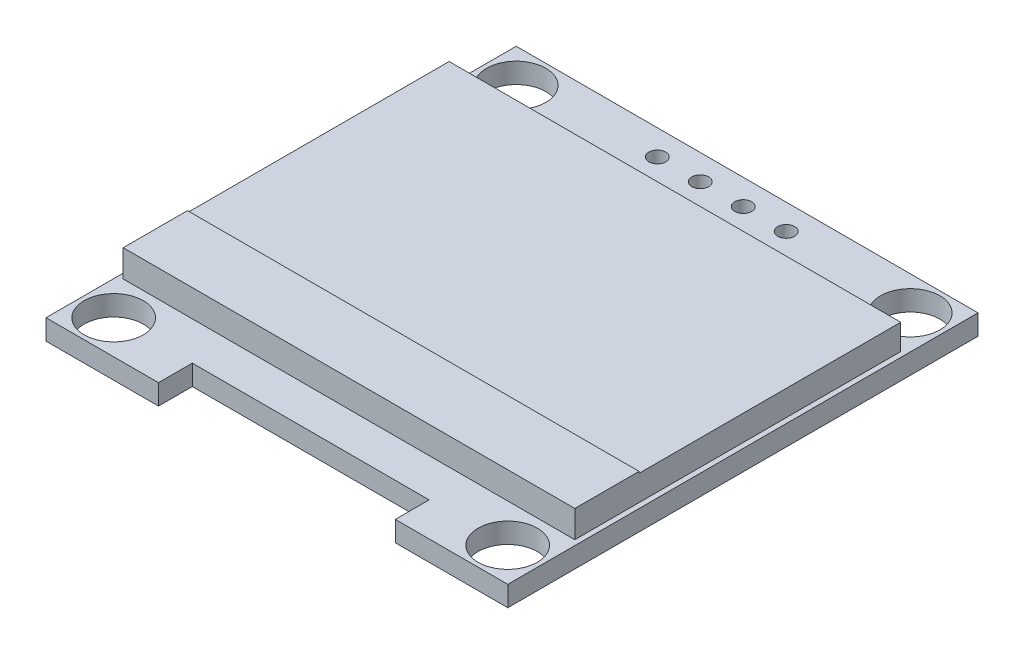
from build123d import *

# Parameters (mm, degrees)
ESQUISSE1_R             = 1.75
ESQUISSE1_R_2           = 0.5
BOSS_EXTRU_2_DEPTH      = 1.2
ESQUISSE9_W             = 26.7
ESQUISSE9_H             = 19.268
BOSS_EXTRU_3_DEPTH      = 1.5
ENL_V_MAT_EXTRU_1_DEPTH = 0.5
ESQUISSE11_W            = 26.7
ESQUISSE11_H            = 3.79988877
BOSS_EXTRU_4_DEPTH      = 0.1


with BuildPart() as part:
    # Esquisse1 → Boss.-Extru.2 (new body)
    with BuildSketch(Plane(origin=(0, 0, 0), x_dir=(1, 0, 0), z_dir=(0, 1, 0))):
        Polygon((0, 0), (0, 27.8), (27.3, 27.8), (27.3, 0), (20.65, 0), (20.65, 2.0001046), (6.65, 2.0001046), (6.65, 0), align=None)
        with Locations((25.29519694, 2.0001046)):
            Circle(ESQUISSE1_R, mode=Mode.SUBTRACT)
        with Locations((2.002692778, 2.0001046)):
            Circle(ESQUISSE1_R, mode=Mode.SUBTRACT)
        with Locations((25.29519694, 25.8)):
            Circle(ESQUISSE1_R, mode=Mode.SUBTRACT)
        with Locations((2, 25.8)):
            Circle(ESQUISSE1_R, mode=Mode.SUBTRACT)
        with Locations((9.84, 26.3)):
            Circle(ESQUISSE1_R_2, mode=Mode.SUBTRACT)
        with Locations((17.46, 26.3)):
            Circle(ESQUISSE1_R_2, mode=Mode.SUBTRACT)
        with Locations((12.38, 26.3)):
            Circle(ESQUISSE1_R_2, mode=Mode.SUBTRACT)
        with Locations((14.92, 26.3)):
            Circle(ESQUISSE1_R_2, mode=Mode.SUBTRACT)
    extrude(amount=BOSS_EXTRU_2_DEPTH)

    # Esquisse9 → Boss.-Extru.3 (add)
    with BuildSketch(Plane(origin=(0, 1.2, 0), x_dir=(1, 0, 0), z_dir=(0, 1, 0))):
        with Locations((13.64759847, 13.9000523)):
            Rectangle(ESQUISSE9_W, ESQUISSE9_H)
    extrude(amount=BOSS_EXTRU_3_DEPTH)

    # Esquisse10 → Enlèv. mat.-Extru.1 (cut)
    with BuildSketch(Plane(origin=(27.506922767, 0, -25.389295394), x_dir=(-1, 0, 0), z_dir=(0, -1, 0))):
        with BuildLine():
            add(Edge.make_bspline(
                [(4.410667941, -14.644029634), (4.475476047, -14.645671114), (4.602764514, -14.648895114), (4.789839411, -14.673574218), (4.968434507, -14.716269608), (5.140004645, -14.77313259), (5.302497622, -14.848986976), (5.457136514, -14.940672124), (5.603553388, -15.049148583), (5.73977477, -15.17357781), (5.86443172, -15.308961264), (5.974257606, -15.453439174), (6.0662999, -15.606137976), (6.141885687, -15.766598807), (6.201184297, -15.934458775), (6.242103341, -16.110612777), (6.268241491, -16.293919468), (6.271297268, -16.418946332), (6.272847428, -16.48237098)],
                knots=[0, 0, 0, 0, 0.000194393, 0.000381804, 0.00056479, 0.000744601, 0.000923091, 0.001101652, 0.001283106, 0.001468738, 0.001654324, 0.001834514, 0.002012231, 0.002188181, 0.002365797, 0.002545211, 0.002729936, 0.002920126, 0.002920126, 0.002920126, 0.002920126], degree=3))
            add(Edge.make_bspline(
                [(6.272847428, -16.48237098), (6.271297495, -16.545328427), (6.268242399, -16.669424847), (6.242073621, -16.851568291), (6.201032621, -17.026658988), (6.142436355, -17.194404641), (6.067210877, -17.354982204), (5.974555706, -17.507969158), (5.865414495, -17.653415657), (5.741207644, -17.789728322), (5.605806602, -17.914725793), (5.460576335, -18.023644668), (5.308783015, -18.117368793), (5.148473307, -18.192152467), (4.98177327, -18.251924387), (4.807190947, -18.292677017), (4.625544393, -18.31896406), (4.501673389, -18.321982576), (4.438712813, -18.323516814)],
                knots=[0, 0, 0, 0, 0.000188789, 0.000372126, 0.000550857, 0.00072758, 0.000904164, 0.001081881, 0.001263191, 0.001448823, 0.00163441, 0.001815159, 0.001992641, 0.002168591, 0.002344885, 0.002522934, 0.002705576, 0.002894365, 0.002894365, 0.002894365, 0.002894365], degree=3))
            add(Edge.make_bspline(
                [(4.438712813, -18.323516814), (4.375288494, -18.321967427), (4.250262278, -18.318913173), (4.066725242, -18.292731768), (3.890447498, -18.251790464), (3.721933147, -18.193281028), (3.561088218, -18.117663797), (3.407598135, -18.025459418), (3.262078988, -17.916052277), (3.125737241, -17.791885703), (3.000988043, -17.656714151), (2.892228667, -17.511879895), (2.800003554, -17.360224439), (2.724640221, -17.201326915), (2.664975762, -17.035955472), (2.624270944, -16.863006994), (2.597934992, -16.683467489), (2.594900145, -16.56122459), (2.593360248, -16.499197903)],
                knots=[0, 0, 0, 0, 0.00019019, 0.000374915, 0.000555011, 0.000732396, 0.00090898, 0.001087298, 0.001268608, 0.00145424, 0.001639827, 0.001819595, 0.001996712, 0.002171394, 0.002346367, 0.002523053, 0.002703612, 0.002889599, 0.002889599, 0.002889599, 0.002889599], degree=3))
            add(Edge.make_bspline(
                [(2.593360248, -16.499197903), (2.593894884, -16.457565234), (2.59495741, -16.374825111), (2.607749103, -16.251958511), (2.626310804, -16.131067853), (2.652912717, -16.012496905), (2.687704384, -15.89653592), (2.728756411, -15.782385157), (2.778896256, -15.671201434), (2.835576904, -15.562458042), (2.898838712, -15.457850136), (2.968714462, -15.358970553), (3.04274983, -15.264989556), (3.123913224, -15.178342552), (3.209529669, -15.096508896), (3.300988047, -15.020746179), (3.397730292, -14.950371228), (3.500172671, -14.886950887), (3.605790946, -14.829591752), (3.714667724, -14.780369901), (3.825324295, -14.73812384), (3.938278943, -14.703883015), (4.053231715, -14.676850979), (4.1704335, -14.658443625), (4.289790926, -14.645619307), (4.370202245, -14.644561805), (4.410667941, -14.644029634)],
                knots=[0, 0, 0, 0, 0.000124849, 0.000248123, 0.000370193, 0.00049164, 0.000612319, 0.000733199, 0.000855287, 0.000977905, 0.001100913, 0.001221706, 0.001340948, 0.001459521, 0.001577551, 0.001696047, 0.001815534, 0.001936153, 0.002057243, 0.002175846, 0.002294342, 0.002412335, 0.002529682, 0.00264829, 0.002768075, 0.00288942, 0.00288942, 0.00288942, 0.00288942], degree=3))
        make_face()
        with BuildLine():
            add(Edge.make_bspline(
                [(4.42609262, -15.003003993), (4.392877987, -15.003408883), (4.326766254, -15.004214793), (4.228481718, -15.014830509), (4.131489784, -15.029960398), (4.035770422, -15.051541918), (3.941724132, -15.080945971), (3.848474291, -15.114786879), (3.756871237, -15.15600797), (3.667217379, -15.202580674), (3.580302304, -15.254129595), (3.498289603, -15.311101362), (3.420966959, -15.372159916), (3.348523692, -15.437447754), (3.28117252, -15.507297356), (3.217587818, -15.580649792), (3.160318237, -15.659601683), (3.10783266, -15.74201209), (3.06086482, -15.827773671), (3.019099465, -15.915983533), (2.984935456, -16.00736122), (2.95707308, -16.100915378), (2.933973269, -16.196497837), (2.919339345, -16.294833686), (2.908606985, -16.395428798), (2.90784714, -16.463410652), (2.907462813, -16.49779566)],
                knots=[0, 0, 0, 0, 9.9599e-05, 0.000198245, 0.000296222, 0.00039402, 0.00049227, 0.000591646, 0.000691452, 0.000793368, 0.000894612, 0.000994383, 0.001092713, 0.00119001, 0.001286696, 0.001383657, 0.001480979, 0.001579008, 0.001676595, 0.001774142, 0.001871547, 0.001968922, 0.002066879, 0.00216624, 0.00226698, 0.002370083, 0.002370083, 0.002370083, 0.002370083], degree=3))
            add(Edge.make_bspline(
                [(2.907462813, -16.49779566), (2.908737675, -16.548357881), (2.911245722, -16.647829411), (2.933203292, -16.793597555), (2.967025267, -16.933685841), (3.016882633, -17.06732775), (3.079233248, -17.195672033), (3.156260138, -17.317580138), (3.247519224, -17.433085012), (3.35118275, -17.541380281), (3.464505457, -17.640226086), (3.584838187, -17.726989494), (3.710891794, -17.800399744), (3.842994997, -17.860204816), (3.980442536, -17.907594554), (4.124120087, -17.940073185), (4.273070547, -17.961448641), (4.374601202, -17.963501397), (4.42609262, -17.964542455)],
                knots=[0, 0, 0, 0, 0.000151605, 0.000298253, 0.000441263, 0.000583229, 0.000725274, 0.000868635, 0.001014928, 0.001166177, 0.001317744, 0.00146543, 0.001610576, 0.001754594, 0.001899821, 0.002045914, 0.002195936, 0.002350312, 0.002350312, 0.002350312, 0.002350312], degree=3))
            add(Edge.make_bspline(
                [(4.42609262, -17.964542455), (4.460702122, -17.96406695), (4.529343158, -17.963123882), (4.631438681, -17.953625206), (4.731694892, -17.938393336), (4.829971172, -17.916462681), (4.926155984, -17.889015474), (5.020650787, -17.856407746), (5.112449077, -17.815726542), (5.202708915, -17.770778591), (5.289105157, -17.719538433), (5.371580689, -17.664500284), (5.448056669, -17.603531663), (5.52044574, -17.53921385), (5.588073429, -17.470250003), (5.650482413, -17.396729781), (5.707462545, -17.318189123), (5.759928192, -17.235903718), (5.806731455, -17.149907465), (5.847510554, -17.061377787), (5.88210667, -16.970532678), (5.910035175, -16.877241106), (5.931920636, -16.781680257), (5.947000556, -16.683722179), (5.957548995, -16.583562837), (5.958344072, -16.515818981), (5.958744864, -16.481669859)],
                knots=[0, 0, 0, 0, 0.000103804, 0.000205874, 0.000307314, 0.000407849, 0.000507719, 0.000607281, 0.000707445, 0.000808723, 0.000909609, 0.001008589, 0.001105934, 0.001202762, 0.001298946, 0.001395452, 0.001491794, 0.001589823, 0.001688026, 0.001785277, 0.001882027, 0.001979402, 0.0020772, 0.002175869, 0.002276609, 0.002379011, 0.002379011, 0.002379011, 0.002379011], degree=3))
            add(Edge.make_bspline(
                [(5.958744864, -16.481669859), (5.958343751, -16.447754354), (5.957548069, -16.380476704), (5.947005595, -16.281015886), (5.931904704, -16.183762674), (5.910141996, -16.089098871), (5.882091843, -15.997000346), (5.847504512, -15.907553599), (5.806719213, -15.820425403), (5.759910988, -15.735831106), (5.707295165, -15.654656368), (5.649800922, -15.577053956), (5.586435573, -15.504481215), (5.519009549, -15.435146521), (5.445838663, -15.370528631), (5.367254369, -15.31060611), (5.284210691, -15.253932836), (5.196283456, -15.202807274), (5.105539502, -15.155593041), (5.012425544, -15.115142038), (4.917996445, -15.080769919), (4.822492332, -15.051452954), (4.725109354, -15.030044924), (4.626505525, -15.014816874), (4.526817267, -15.004218488), (4.459774047, -15.003410109), (4.42609262, -15.003003993)],
                knots=[0, 0, 0, 0, 0.000101701, 0.000201743, 0.00029972, 0.000396835, 0.000492868, 0.000588308, 0.000684288, 0.000781261, 0.000878109, 0.000974304, 0.001070733, 0.001166917, 0.001264269, 0.001363274, 0.001463228, 0.001565678, 0.001668217, 0.001769947, 0.001869982, 0.001969573, 0.002069423, 0.002168785, 0.002268827, 0.002369827, 0.002369827, 0.002369827, 0.002369827], degree=3))
        make_face(mode=Mode.SUBTRACT)
        Polygon((6.990796146, -14.733773224), (7.30489871, -14.733773224), (7.30489871, -17.874798865), (8.651052556, -17.874798865), (8.651052556, -18.233773224), (6.990796146, -18.233773224), align=None)
        Polygon((9.234385889, -14.733773224), (11.208744864, -14.733773224), (11.208744864, -15.092747583), (9.548488454, -15.092747583), (9.548488454, -16.16967066), (11.208744864, -16.16967066), (11.208744864, -16.528645019), (9.548488454, -16.528645019), (9.548488454, -17.874798865), (11.208744864, -17.874798865), (11.208744864, -18.233773224), (9.234385889, -18.233773224), align=None)
        with BuildLine():
            Line((11.836949992, -18.233773224), (11.836949992, -14.733773224))
            Line((11.836949992, -14.733773224), (12.543680761, -14.733773224))
            add(Edge.make_bspline(
                [(12.543680761, -14.733773224), (12.605149749, -14.734215794), (12.723907515, -14.735070837), (12.895519962, -14.740492228), (13.054303725, -14.750082694), (13.199736584, -14.76405222), (13.332217796, -14.781205254), (13.451376404, -14.802705658), (13.557828547, -14.828093828), (13.623297987, -14.849739279), (13.654257684, -14.859975147)],
                knots=[0, 0, 0, 0, 0.000184407, 0.000356273, 0.000515031, 0.000661537, 0.000794508, 0.000915664, 0.001024665, 0.001122454, 0.001122454, 0.001122454, 0.001122454], degree=3))
            add(Edge.make_bspline(
                [(13.654257684, -14.859975147), (13.694752424, -14.875405853), (13.774823616, -14.905917347), (13.888830738, -14.963473648), (13.996156101, -15.02868675), (14.097375246, -15.101642613), (14.190176073, -15.184406961), (14.278183969, -15.273464047), (14.357798693, -15.372052387), (14.430706989, -15.478127375), (14.496442649, -15.590439427), (14.553581807, -15.708774536), (14.6010358, -15.832531744), (14.640429027, -15.961366892), (14.671475484, -16.09556327), (14.692657416, -16.235277136), (14.706628406, -16.379956325), (14.708032457, -16.478130789), (14.708744864, -16.527943897)],
                knots=[0, 0, 0, 0, 0.000129935, 0.000256923, 0.000382457, 0.000506429, 0.000630624, 0.000755071, 0.000881654, 0.001010204, 0.001140916, 0.00127168, 0.001403968, 0.001538146, 0.001675568, 0.001816774, 0.001961818, 0.002111216, 0.002111216, 0.002111216, 0.002111216], degree=3))
            add(Edge.make_bspline(
                [(14.708744864, -16.527943897), (14.708115896, -16.571205136), (14.70687645, -16.656455924), (14.695747134, -16.78209682), (14.679570814, -16.904010391), (14.654526616, -17.021616091), (14.624124103, -17.135944309), (14.585159952, -17.245776554), (14.540524456, -17.352120363), (14.488474577, -17.453537839), (14.431333192, -17.549621211), (14.370011449, -17.640196739), (14.304574753, -17.723971961), (14.234399121, -17.801200573), (14.160391404, -17.871766152), (14.082067073, -17.936258167), (13.999224023, -17.993414722), (13.9122333, -18.04548183), (13.818557171, -18.090902186), (13.716421305, -18.129332195), (13.605390127, -18.161178811), (13.48573617, -18.187749707), (13.357252692, -18.208827009), (13.219813726, -18.222953402), (13.073630436, -18.232506334), (12.973251171, -18.233342728), (12.921585409, -18.233773224)],
                knots=[0, 0, 0, 0, 0.000129755, 0.000255696, 0.000378151, 0.000498469, 0.000616165, 0.000732801, 0.000847787, 0.000961923, 0.00107447, 0.001182981, 0.001289856, 0.001393094, 0.001495748, 0.001596383, 0.00169713, 0.001797413, 0.001900265, 0.002008995, 0.002124372, 0.002246504, 0.002376522, 0.002514729, 0.002660846, 0.00281582, 0.00281582, 0.00281582, 0.00281582], degree=3))
            Line((12.921585409, -18.233773224), (11.836949992, -18.233773224))
        make_face()
        with BuildLine():
            Line((12.151052556, -17.874798865), (12.552795345, -17.874798865))
            add(Edge.make_bspline(
                [(12.552795345, -17.874798865), (12.610523715, -17.874550769), (12.721556514, -17.874073588), (12.881214511, -17.869886385), (13.027093908, -17.863044448), (13.159215417, -17.85346937), (13.277504441, -17.840800755), (13.382208191, -17.826675852), (13.472983449, -17.809078401), (13.527912886, -17.793127442), (13.553296146, -17.785756397)],
                knots=[0, 0, 0, 0, 0.000173183, 0.000333094, 0.000479096, 0.000611272, 0.000730431, 0.000835931, 0.000928194, 0.001007458, 0.001007458, 0.001007458, 0.001007458], degree=3))
            add(Edge.make_bspline(
                [(13.553296146, -17.785756397), (13.585244508, -17.774504839), (13.648378146, -17.752270466), (13.739259231, -17.711712804), (13.824016236, -17.663670735), (13.904126261, -17.610268461), (13.978452917, -17.549622459), (14.047877033, -17.48305147), (14.112258834, -17.410216695), (14.170933142, -17.331208533), (14.223441446, -17.246518738), (14.268912676, -17.156979904), (14.308764207, -17.063573094), (14.3400428, -16.964863935), (14.364558384, -16.861734877), (14.381923072, -16.754178663), (14.392737797, -16.642215381), (14.393999245, -16.566063257), (14.3946423, -16.527242775)],
                knots=[0, 0, 0, 0, 0.000101593, 0.000200759, 0.000298073, 0.000393552, 0.000489254, 0.000585454, 0.000681817, 0.000780535, 0.000880346, 0.000980374, 0.001081551, 0.001184655, 0.001290601, 0.001399295, 0.001511268, 0.001627707, 0.001627707, 0.001627707, 0.001627707], degree=3))
            add(Edge.make_bspline(
                [(14.3946423, -16.527242775), (14.394129012, -16.486309295), (14.393120655, -16.405895111), (14.380446344, -16.287904415), (14.361924789, -16.174423765), (14.335141103, -16.065445569), (14.301010224, -15.960757217), (14.258415582, -15.860937707), (14.209748963, -15.764932838), (14.151845626, -15.674958472), (14.088430033, -15.589865363), (14.018052153, -15.511910448), (13.941830115, -15.440916147), (13.860595265, -15.375776835), (13.772058166, -15.319113159), (13.678304475, -15.268426478), (13.577958804, -15.225410586), (13.508146108, -15.202531724), (13.472667139, -15.190904634)],
                knots=[0, 0, 0, 0, 0.000122746, 0.000241136, 0.000355593, 0.000467485, 0.000577457, 0.000685538, 0.00079278, 0.000899951, 0.001006101, 0.00111085, 0.001214524, 0.001318328, 0.001422759, 0.001529413, 0.00163777, 0.001749741, 0.001749741, 0.001749741, 0.001749741], degree=3))
            add(Edge.make_bspline(
                [(13.472667139, -15.190904634), (13.443315993, -15.182788206), (13.380907403, -15.165530454), (13.279067939, -15.146705081), (13.164452789, -15.130100582), (13.036553088, -15.116042543), (12.895514629, -15.105955222), (12.741228941, -15.098383907), (12.573629337, -15.093277274), (12.457446803, -15.092928567), (12.397146306, -15.092747583)],
                knots=[0, 0, 0, 0, 9.1321e-05, 0.000194173, 0.000310382, 0.000438754, 0.000580072, 0.000734511, 0.000902151, 0.001083046, 0.001083046, 0.001083046, 0.001083046], degree=3))
            Line((12.397146306, -15.092747583), (12.151052556, -15.092747583))
            Line((12.151052556, -15.092747583), (12.151052556, -17.874798865))
        make_face(mode=Mode.SUBTRACT)
        with BuildLine():
            add(Edge.make_bspline(
                [(16.458744864, -16.485175468), (16.459072882, -16.42907808), (16.459710062, -16.320108096), (16.466798483, -16.161323453), (16.478573825, -16.012363164), (16.494711198, -15.873220098), (16.514349178, -15.743858334), (16.540564665, -15.624623577), (16.570377468, -15.51496397), (16.604929913, -15.414521922), (16.643917702, -15.321944219), (16.686351963, -15.235519017), (16.733916758, -15.155377085), (16.78389367, -15.080239295), (16.838305742, -15.0113356), (16.895604533, -14.947692937), (16.958026409, -14.890782187), (17.023449417, -14.838935884), (17.092465881, -14.793486413), (17.163108548, -14.753453674), (17.235863653, -14.719253807), (17.310929836, -14.692363371), (17.387632394, -14.670152524), (17.466239461, -14.654963577), (17.546880825, -14.645406668), (17.60131226, -14.644493), (17.628917139, -14.644029634)],
                knots=[0, 0, 0, 0, 0.000168282, 0.000326891, 0.000476705, 0.00061646, 0.000747059, 0.00086904, 0.000982494, 0.001087814, 0.001187428, 0.001283689, 0.001376399, 0.001466822, 0.001554203, 0.001639568, 0.001723424, 0.001807301, 0.001889751, 0.001971063, 0.002050735, 0.002130583, 0.002210036, 0.002290062, 0.002370508, 0.002453288, 0.002453288, 0.002453288, 0.002453288], degree=3))
            add(Edge.make_bspline(
                [(17.628917139, -14.644029634), (17.656752618, -14.644517449), (17.712108627, -14.64548756), (17.793949002, -14.654811503), (17.873898684, -14.670282626), (17.951616823, -14.6922036), (18.027741809, -14.719399277), (18.101678217, -14.753486394), (18.173885298, -14.793165262), (18.243215586, -14.839789139), (18.310430201, -14.891771415), (18.373878164, -14.950534084), (18.43356525, -15.015483803), (18.490240555, -15.085925667), (18.542296153, -15.163210752), (18.591869585, -15.245994862), (18.636241621, -15.335725727), (18.678976296, -15.430906194), (18.715863283, -15.534169853), (18.749129528, -15.644934614), (18.776008496, -15.764508801), (18.798397769, -15.892265046), (18.815742665, -16.028672529), (18.828375307, -16.173438845), (18.835048392, -16.326659235), (18.836305093, -16.431417084), (18.836949992, -16.485175468)],
                knots=[0, 0, 0, 0, 8.3481e-05, 0.000166017, 0.000246731, 0.000327534, 0.000408041, 0.000488986, 0.000571522, 0.000654944, 0.000739373, 0.000826202, 0.000914021, 0.001003809, 0.001097153, 0.001193347, 0.001293057, 0.001397277, 0.001506176, 0.001621751, 0.001744038, 0.001873599, 0.002010742, 0.002156422, 0.002309427, 0.002470709, 0.002470709, 0.002470709, 0.002470709], degree=3))
            add(Edge.make_bspline(
                [(18.836949992, -16.485175468), (18.836298407, -16.538699375), (18.835028822, -16.642988527), (18.828450115, -16.795519503), (18.815491484, -16.939517546), (18.799281495, -17.075328008), (18.776830532, -17.202385627), (18.749225366, -17.321130076), (18.718575043, -17.432074147), (18.680740249, -17.534308959), (18.639329539, -17.629260682), (18.594274343, -17.71792783), (18.546004517, -17.801094123), (18.493415772, -17.87809387), (18.437362358, -17.949472527), (18.37664457, -18.01397015), (18.312973984, -18.073140821), (18.245561569, -18.125792449), (18.175150017, -18.171877254), (18.10319094, -18.213091104), (18.028407557, -18.246323799), (17.952494604, -18.27485884), (17.874366238, -18.296659292), (17.794119848, -18.311733147), (17.712163612, -18.322304996), (17.656762047, -18.323111476), (17.628917139, -18.323516814)],
                knots=[0, 0, 0, 0, 0.000160581, 0.000312886, 0.000457868, 0.000594226, 0.000723097, 0.000844701, 0.000959884, 0.001068125, 0.001171421, 0.001270505, 0.001366343, 0.001459687, 0.001550023, 0.00163832, 0.001725149, 0.001810562, 0.001894568, 0.001977446, 0.00205903, 0.002139777, 0.00222058, 0.002301983, 0.002384599, 0.00246808, 0.00246808, 0.00246808, 0.00246808], degree=3))
            add(Edge.make_bspline(
                [(17.628917139, -18.323516814), (17.601313025, -18.323050458), (17.546883101, -18.322130896), (17.466230675, -18.312617165), (17.387948232, -18.297321662), (17.311649478, -18.275905058), (17.236942963, -18.249690221), (17.164846676, -18.215536538), (17.094558992, -18.176202469), (17.026267436, -18.131407047), (16.961255275, -18.080085364), (16.89915667, -18.023321075), (16.841531651, -17.959697664), (16.787897555, -17.890219741), (16.736923467, -17.815526499), (16.690034094, -17.734598126), (16.64666324, -17.647755515), (16.607019749, -17.554437604), (16.571871086, -17.453282677), (16.540823377, -17.343133498), (16.51630922, -17.223017862), (16.495326265, -17.093900495), (16.478401882, -16.955226564), (16.466847556, -16.806920786), (16.459706241, -16.649075577), (16.459071171, -16.540805803), (16.458744864, -16.485175468)],
                knots=[0, 0, 0, 0, 8.278e-05, 0.000163226, 0.000243252, 0.00032184, 0.00040079, 0.000480463, 0.00056082, 0.000642298, 0.000725191, 0.000809047, 0.000894412, 0.000982346, 0.001072188, 0.001165503, 0.001262704, 0.001363236, 0.001469448, 0.001583766, 0.001706286, 0.001836995, 0.001976138, 0.002125253, 0.002283161, 0.002450041, 0.002450041, 0.002450041, 0.002450041], degree=3))
        make_face()
        with BuildLine():
            add(Edge.make_bspline(
                [(16.772847428, -16.483773224), (16.772966875, -16.530521923), (16.773198698, -16.621251968), (16.779254899, -16.753095229), (16.787505131, -16.876065557), (16.798146428, -16.990319094), (16.813949377, -17.095469106), (16.831656164, -17.192238789), (16.853204254, -17.280116026), (16.878699272, -17.359703837), (16.907738369, -17.432352906), (16.939444232, -17.499954121), (16.973504955, -17.563306057), (17.011624106, -17.621839666), (17.053139169, -17.67574583), (17.097112428, -17.725978662), (17.145185013, -17.770775643), (17.211688755, -17.824502498), (17.299485229, -17.880021632), (17.410105685, -17.928367722), (17.523774136, -17.958750178), (17.600925386, -17.962613934), (17.639433966, -17.964542455)],
                knots=[0, 0, 0, 0, 0.000140231, 0.000272162, 0.000395845, 0.00050998, 0.000616273, 0.00071473, 0.000805025, 0.000887508, 0.000965234, 0.00103957, 0.001111417, 0.001180842, 0.001248855, 0.001315406, 0.001380877, 0.0014457, 0.001571746, 0.00169106, 0.001806864, 0.001922266, 0.001922266, 0.001922266, 0.001922266], degree=3))
            add(Edge.make_bspline(
                [(17.639433966, -17.964542455), (17.678191638, -17.962944674), (17.755626961, -17.959752411), (17.868760756, -17.928953674), (17.978591026, -17.882484134), (18.064662967, -17.827536629), (18.13014551, -17.775208299), (18.1770625, -17.730593651), (18.220124549, -17.680637784), (18.260966624, -17.626738488), (18.298425699, -17.567866004), (18.332488837, -17.504303428), (18.363572185, -17.435874251), (18.38128123, -17.388104511), (18.390335409, -17.363681077)],
                knots=[0, 0, 0, 0, 0.000116044, 0.000231848, 0.000349318, 0.000472837, 0.000536674, 0.000600645, 0.000666733, 0.000734322, 0.000803367, 0.000875831, 0.000950509, 0.001028633, 0.001028633, 0.001028633, 0.001028633], degree=3))
            add(Edge.make_bspline(
                [(18.390335409, -17.363681077), (18.400887176, -17.332451337), (18.42231179, -17.269041573), (18.449923565, -17.170677921), (18.471668964, -17.067475157), (18.49123233, -16.96005004), (18.504585385, -16.847610339), (18.515333199, -16.730503955), (18.521663886, -16.608642593), (18.522448637, -16.525847602), (18.522847428, -16.483773224)],
                knots=[0, 0, 0, 0, 9.8886e-05, 0.00020078, 0.000306259, 0.000415188, 0.00052824, 0.000645799, 0.000767957, 0.000894177, 0.000894177, 0.000894177, 0.000894177], degree=3))
            add(Edge.make_bspline(
                [(18.522847428, -16.483773224), (18.522297239, -16.441705651), (18.521220951, -16.359412487), (18.517106963, -16.238894306), (18.506483389, -16.124426545), (18.49468427, -16.015516072), (18.477287049, -15.91276577), (18.458529242, -15.815315464), (18.43332803, -15.72437244), (18.406408255, -15.638512858), (18.375597859, -15.558712203), (18.341682125, -15.484598417), (18.305460366, -15.415813692), (18.266118126, -15.352546751), (18.224122443, -15.294514208), (18.178364893, -15.242879613), (18.130660521, -15.196042645), (18.063843335, -15.142580076), (17.976369045, -15.088068381), (17.867523398, -15.037902621), (17.754252753, -15.009094328), (17.677679299, -15.005032641), (17.639433966, -15.003003993)],
                knots=[0, 0, 0, 0, 0.000126219, 0.000246912, 0.000361616, 0.00047102, 0.00057545, 0.000674176, 0.000768567, 0.000858368, 0.000944043, 0.001024988, 0.001102772, 0.001177091, 0.00124833, 0.001317386, 0.001383826, 0.001448649, 0.001573728, 0.001692043, 0.001806995, 0.001921698, 0.001921698, 0.001921698, 0.001921698], degree=3))
            add(Edge.make_bspline(
                [(17.639433966, -15.003003993), (17.600723374, -15.00503544), (17.523231669, -15.009102034), (17.408783714, -15.037795288), (17.299079362, -15.087808253), (17.211836388, -15.142760626), (17.144972601, -15.195098937), (17.097889908, -15.240485391), (17.053743736, -15.290131646), (17.013076035, -15.344533561), (16.974986752, -15.402998928), (16.94000574, -15.465987693), (16.90848841, -15.533819057), (16.879403874, -15.606435492), (16.853831086, -15.686016437), (16.832737123, -15.77378543), (16.813250069, -15.870247322), (16.799454801, -15.97596683), (16.787191045, -16.090248983), (16.779309697, -16.213526302), (16.773178439, -16.345590682), (16.772959975, -16.436789841), (16.772847428, -16.483773224)],
                knots=[0, 0, 0, 0, 0.000116101, 0.000232413, 0.000351368, 0.000476447, 0.000540832, 0.000605795, 0.000672346, 0.000739935, 0.00080936, 0.000881545, 0.00095588, 0.001033607, 0.001116089, 0.001206384, 0.001304286, 0.001411174, 0.001526077, 0.001649061, 0.001781692, 0.001922624, 0.001922624, 0.001922624, 0.001922624], degree=3))
        make_face(mode=Mode.SUBTRACT)
        with BuildLine():
            add(Edge.make_bspline(
                [(19.711949992, -17.695311685), (19.731440204, -17.696469852), (19.769648487, -17.698740303), (19.824887615, -17.714316976), (19.874882275, -17.741975637), (19.919414519, -17.778838415), (19.956120996, -17.823534078), (19.984765348, -17.873129987), (20.000206333, -17.92883158), (20.002460245, -17.967261255), (20.003616659, -17.986978352)],
                knots=[0, 0, 0, 0, 5.8463e-05, 0.000114609, 0.000170453, 0.000228714, 0.000286975, 0.000343156, 0.000399303, 0.000458464, 0.000458464, 0.000458464, 0.000458464], degree=3))
            add(Edge.make_bspline(
                [(20.003616659, -17.986978352), (20.002421058, -18.006221682), (20.000063351, -18.044169246), (19.984800743, -18.099450708), (19.955902692, -18.149077613), (19.9196677, -18.194379751), (19.874871266, -18.231320621), (19.82476942, -18.258743966), (19.769778161, -18.275435946), (19.731461838, -18.277562243), (19.711949992, -18.278645019)],
                knots=[0, 0, 0, 0, 5.7765e-05, 0.000113912, 0.000170093, 0.000228896, 0.000287156, 0.000343, 0.000399343, 0.000457806, 0.000457806, 0.000457806, 0.000457806], degree=3))
            add(Edge.make_bspline(
                [(19.711949992, -18.278645019), (19.692424086, -18.277601422), (19.654304404, -18.275564047), (19.59951841, -18.25840124), (19.549111441, -18.23157778), (19.504323729, -18.194310871), (19.467785258, -18.149310727), (19.440159875, -18.099108931), (19.423569726, -18.044327493), (19.421387853, -18.00625285), (19.420283325, -17.986978352)],
                knots=[0, 0, 0, 0, 5.8463e-05, 0.000114135, 0.000170596, 0.000228856, 0.000287659, 0.000343502, 0.000399846, 0.000457611, 0.000457611, 0.000457611, 0.000457611], degree=3))
            add(Edge.make_bspline(
                [(19.420283325, -17.986978352), (19.421345425, -17.967228973), (19.423419043, -17.928670733), (19.440194703, -17.873471625), (19.467570915, -17.823303186), (19.50457631, -17.778906606), (19.549100606, -17.741719303), (19.599396811, -17.71465451), (19.654436352, -17.698614098), (19.69244629, -17.696431581), (19.711949992, -17.695311685)],
                knots=[0, 0, 0, 0, 5.9161e-05, 0.000115504, 0.000171348, 0.000229609, 0.000287869, 0.00034433, 0.000399803, 0.000458266, 0.000458266, 0.000458266, 0.000458266], degree=3))
        make_face()
        with BuildLine():
            Line((21.21515512, -18.323516814), (20.964153518, -18.148937487))
            Line((20.964153518, -18.148937487), (21.937310569, -16.726361365))
            add(Edge.make_bspline(
                [(21.937310569, -16.726361365), (21.875219833, -16.733954428), (21.752959713, -16.748905593), (21.629822611, -16.751652248), (21.569221627, -16.753003993)],
                knots=[0, 0, 0, 0, 0.000187529, 0.000369255, 0.000369255, 0.000369255, 0.000369255], degree=3))
            add(Edge.make_bspline(
                [(21.569221627, -16.753003993), (21.532479579, -16.752062917), (21.460358152, -16.750215666), (21.354326499, -16.735573858), (21.252440939, -16.71302373), (21.154971583, -16.679374975), (21.061552078, -16.637556766), (20.972386365, -16.585699752), (20.887594474, -16.524693461), (20.808087064, -16.454860469), (20.735775325, -16.378182417), (20.671352028, -16.297026774), (20.617810896, -16.210450803), (20.57333431, -16.120220583), (20.539603857, -16.025039233), (20.515041319, -15.925989832), (20.499918965, -15.82237819), (20.498119869, -15.75185306), (20.497206402, -15.716044859)],
                knots=[0, 0, 0, 0, 0.000110185, 0.000216284, 0.000320547, 0.000422759, 0.000525058, 0.000627155, 0.000731643, 0.000837964, 0.0009441, 0.00104747, 0.001148247, 0.001248901, 0.001348697, 0.001450555, 0.001554666, 0.00166205, 0.00166205, 0.00166205, 0.00166205], degree=3))
            add(Edge.make_bspline(
                [(20.497206402, -15.716044859), (20.498940837, -15.667076206), (20.502345181, -15.570960674), (20.529743698, -15.430526905), (20.574804037, -15.297740362), (20.637632414, -15.172950168), (20.716767135, -15.057951429), (20.811875726, -14.954342819), (20.92237969, -14.863597966), (21.045761709, -14.785593888), (21.17911473, -14.722858891), (21.318783388, -14.67661959), (21.463697508, -14.649420843), (21.561865178, -14.645834981), (21.611288934, -14.644029634)],
                knots=[0, 0, 0, 0, 0.000146818, 0.000288173, 0.000427413, 0.000566316, 0.000705952, 0.000844895, 0.000986821, 0.001133677, 0.001281714, 0.001427825, 0.001574003, 0.00172222, 0.00172222, 0.00172222, 0.00172222], degree=3))
            add(Edge.make_bspline(
                [(21.611288934, -14.644029634), (21.659777354, -14.645859797), (21.755585901, -14.649476027), (21.896474907, -14.675959996), (22.031415924, -14.720596669), (22.159660911, -14.782281233), (22.278400323, -14.85960214), (22.385176134, -14.951736664), (22.477551673, -15.058742191), (22.555375554, -15.178030681), (22.617845595, -15.306197662), (22.662917878, -15.439981585), (22.690663516, -15.578420306), (22.694159844, -15.67221478), (22.695924351, -15.719550468)],
                knots=[0, 0, 0, 0, 0.000145418, 0.000287333, 0.000428343, 0.000570713, 0.000713061, 0.00085223, 0.000992387, 0.001135706, 0.001278381, 0.001418948, 0.001558239, 0.001700158, 0.001700158, 0.001700158, 0.001700158], degree=3))
            add(Edge.make_bspline(
                [(22.695924351, -15.719550468), (22.694745942, -15.756294235), (22.692355834, -15.830819775), (22.675619527, -15.944050118), (22.647199342, -16.059501348), (22.614947643, -16.157222943), (22.583815476, -16.237931393), (22.554514344, -16.301682973), (22.52200219, -16.368784236), (22.484083425, -16.438531574), (22.443321128, -16.511814109), (22.397261852, -16.587896825), (22.34695628, -16.666881818), (22.31112656, -16.720128906), (22.292779319, -16.747395019)],
                knots=[0, 0, 0, 0, 0.000110219, 0.000223552, 0.000342587, 0.000466527, 0.000532018, 0.000601997, 0.000676938, 0.00075567, 0.000840114, 0.000928491, 0.001022434, 0.001121023, 0.001121023, 0.001121023, 0.001121023], degree=3))
            Line((22.292779319, -16.747395019), (21.21515512, -18.323516814))
        make_face()
        with BuildLine():
            add(Edge.make_bspline(
                [(21.627414736, -16.394029634), (21.65524875, -16.39326925), (21.709432113, -16.391789042), (21.788809412, -16.3827798), (21.863733615, -16.366805814), (21.934404865, -16.343886102), (22.001531766, -16.316229433), (22.064048095, -16.281017447), (22.12200617, -16.239000812), (22.175794097, -16.191790796), (22.223558097, -16.139340213), (22.266101127, -16.084443106), (22.302261695, -16.026858496), (22.330824972, -15.965865234), (22.354309547, -15.902948025), (22.370527559, -15.83709367), (22.379511893, -15.768645269), (22.381043468, -15.722146611), (22.381821787, -15.698516814)],
                knots=[0, 0, 0, 0, 8.3507e-05, 0.00016256, 0.000239294, 0.000312908, 0.000385178, 0.000456751, 0.000527578, 0.000599603, 0.000671055, 0.000740051, 0.000807755, 0.000874553, 0.000941763, 0.001008931, 0.001077548, 0.001148448, 0.001148448, 0.001148448, 0.001148448], degree=3))
            add(Edge.make_bspline(
                [(22.381821787, -15.698516814), (22.381152118, -15.674877148), (22.379832452, -15.628292288), (22.369245153, -15.559742549), (22.35061993, -15.494049288), (22.325629445, -15.430852858), (22.292709207, -15.370672486), (22.253205721, -15.312752614), (22.206273272, -15.257460486), (22.152270705, -15.206096503), (22.094036152, -15.158748604), (22.031975652, -15.116962528), (21.966600736, -15.081941331), (21.898310246, -15.053042361), (21.826961897, -15.030490586), (21.752597909, -15.014273221), (21.674842504, -15.005301466), (21.622061218, -15.003779572), (21.595163133, -15.003003993)],
                knots=[0, 0, 0, 0, 7.09e-05, 0.000139717, 0.000207422, 0.000275384, 0.000343146, 0.000412766, 0.000485392, 0.000560268, 0.000636041, 0.000710323, 0.000784354, 0.000858188, 0.000932471, 0.001008519, 0.001086179, 0.001166885, 0.001166885, 0.001166885, 0.001166885], degree=3))
            add(Edge.make_bspline(
                [(21.595163133, -15.003003993), (21.56849898, -15.003780825), (21.51618413, -15.005304962), (21.439119971, -15.014256167), (21.365258803, -15.030599652), (21.294117183, -15.053031915), (21.225828722, -15.081943487), (21.16045689, -15.116964363), (21.098381873, -15.158738985), (21.040203152, -15.206133757), (20.98610523, -15.257221403), (20.939979701, -15.312994832), (20.900385809, -15.370642357), (20.867510806, -15.430860865), (20.842508289, -15.494047151), (20.823886287, -15.559743127), (20.813298122, -15.628292138), (20.811978575, -15.674877098), (20.811308966, -15.698516814)],
                knots=[0, 0, 0, 0, 8.0005e-05, 0.000156969, 0.000232332, 0.000306614, 0.000380449, 0.000454479, 0.000528762, 0.000604535, 0.000679411, 0.000751586, 0.000821205, 0.000888968, 0.00095693, 0.001024634, 0.001093451, 0.001164351, 0.001164351, 0.001164351, 0.001164351], degree=3))
            add(Edge.make_bspline(
                [(20.811308966, -15.698516814), (20.811914893, -15.722165012), (20.81310989, -15.768803589), (20.824637679, -15.837329981), (20.843915959, -15.903018175), (20.86973535, -15.966506882), (20.90373694, -16.027178741), (20.945460788, -16.084746103), (20.994366334, -16.139861553), (21.049799822, -16.191668765), (21.110467983, -16.23922094), (21.175264729, -16.280751322), (21.243074566, -16.315823767), (21.314136196, -16.34396515), (21.387922996, -16.366576814), (21.465098128, -16.382750359), (21.545406365, -16.391702626), (21.599816347, -16.393246523), (21.627414736, -16.394029634)],
                knots=[0, 0, 0, 0, 7.09e-05, 0.000139828, 0.000207725, 0.00027595, 0.000345002, 0.000415829, 0.000488844, 0.000565728, 0.000643147, 0.000719775, 0.000796287, 0.0008718, 0.000948761, 0.001027552, 0.001107998, 0.001190805, 0.001190805, 0.001190805, 0.001190805], degree=3))
        make_face(mode=Mode.SUBTRACT)
        with BuildLine():
            Line((24.760026915, -14.644029634), (25.001913934, -14.834033641))
            Line((25.001913934, -14.834033641), (24.077134287, -16.248196301))
            add(Edge.make_bspline(
                [(24.077134287, -16.248196301), (24.138704564, -16.23838244), (24.258804351, -16.219239395), (24.380370249, -16.21608145), (24.439614255, -16.214542455)],
                knots=[0, 0, 0, 0, 0.000186809, 0.000364392, 0.000364392, 0.000364392, 0.000364392], degree=3))
            add(Edge.make_bspline(
                [(24.439614255, -16.214542455), (24.475186751, -16.215498566), (24.545210152, -16.217380644), (24.648016954, -16.231864495), (24.74680589, -16.254689606), (24.841167502, -16.287961862), (24.931440484, -16.330464217), (25.01814288, -16.381403087), (25.09964489, -16.443408767), (25.176996069, -16.512673723), (25.247223167, -16.589390708), (25.309399222, -16.670792044), (25.361626014, -16.756792925), (25.403999936, -16.847349791), (25.436904814, -16.942323051), (25.460892459, -17.04159119), (25.475072052, -17.145222662), (25.476997543, -17.215700837), (25.477975633, -17.251501589)],
                knots=[0, 0, 0, 0, 0.000106683, 0.000210003, 0.00031085, 0.000410412, 0.000509526, 0.000609808, 0.000711471, 0.00081622, 0.000920922, 0.001023007, 0.001123049, 0.001222163, 0.001322387, 0.001424078, 0.001528093, 0.001635477, 0.001635477, 0.001635477, 0.001635477], degree=3))
            add(Edge.make_bspline(
                [(25.477975633, -17.251501589), (25.476552528, -17.300481293), (25.473752195, -17.396861759), (25.445848399, -17.537238466), (25.402488754, -17.670970981), (25.340511225, -17.795924153), (25.263528842, -17.911926722), (25.16965125, -18.014712188), (25.062207761, -18.106382225), (24.940720963, -18.183038844), (24.809977999, -18.245641895), (24.672626002, -18.290607137), (24.529998855, -18.318290607), (24.433194247, -18.321761209), (24.384225633, -18.323516814)],
                knots=[0, 0, 0, 0, 0.000146776, 0.00028882, 0.000427614, 0.000567461, 0.000705914, 0.000843912, 0.000983689, 0.001128394, 0.001273595, 0.001417489, 0.001560911, 0.001707729, 0.001707729, 0.001707729, 0.001707729], degree=3))
            add(Edge.make_bspline(
                [(24.384225633, -18.323516814), (24.337128932, -18.321988608), (24.243838614, -18.3189615), (24.10660582, -18.291995562), (23.974742803, -18.248288459), (23.849173422, -18.188074181), (23.732852809, -18.112016298), (23.628787173, -18.020454019), (23.537495398, -17.915344554), (23.461520777, -17.796704206), (23.401262045, -17.669214249), (23.35607212, -17.536277092), (23.329675877, -17.398377111), (23.32598732, -17.304895972), (23.324129479, -17.257811685)],
                knots=[0, 0, 0, 0, 0.000141176, 0.000279646, 0.000417774, 0.000557008, 0.000696242, 0.000833365, 0.000971544, 0.001112541, 0.001254608, 0.001393623, 0.001532781, 0.001674001, 0.001674001, 0.001674001, 0.001674001], degree=3))
            add(Edge.make_bspline(
                [(23.324129479, -17.257811685), (23.325310924, -17.221767102), (23.327723209, -17.14817095), (23.3445666, -17.036706922), (23.371631394, -16.922655841), (23.401941641, -16.825901647), (23.433967251, -16.746640125), (23.46061979, -16.682736634), (23.493793786, -16.616975561), (23.529167168, -16.547101925), (23.569924036, -16.474916493), (23.614239686, -16.399212823), (23.663339337, -16.321194895), (23.697759499, -16.2682507), (23.715355441, -16.241185083)],
                knots=[0, 0, 0, 0, 0.000108118, 0.000220757, 0.000337422, 0.000459596, 0.000524434, 0.000593848, 0.000667222, 0.000745302, 0.000828791, 0.000915849, 0.00100845, 0.001105299, 0.001105299, 0.001105299, 0.001105299], degree=3))
            Line((23.715355441, -16.241185083), (24.760026915, -14.644029634))
        make_face()
        with BuildLine():
            add(Edge.make_bspline(
                [(24.373708806, -16.573516814), (24.347046561, -16.574294857), (24.294967452, -16.575814603), (24.218560037, -16.584639855), (24.146246786, -16.60125892), (24.077069652, -16.622425252), (24.012321949, -16.651528312), (23.951533109, -16.686880111), (23.894468057, -16.728501289), (23.841724506, -16.7758022), (23.793904842, -16.827590233), (23.752723712, -16.883059755), (23.717201311, -16.940873958), (23.688319493, -17.001515901), (23.665829417, -17.0649624), (23.649561166, -17.13092165), (23.640507415, -17.199835956), (23.639001183, -17.246568458), (23.638232043, -17.270431878)],
                knots=[0, 0, 0, 0, 8.0005e-05, 0.000156272, 0.000230267, 0.000302332, 0.000372951, 0.000442698, 0.000512957, 0.000584457, 0.000654919, 0.00072405, 0.000791387, 0.000858185, 0.000925156, 0.000993006, 0.001061623, 0.001133223, 0.001133223, 0.001133223, 0.001133223], degree=3))
            add(Edge.make_bspline(
                [(23.638232043, -17.270431878), (23.638858405, -17.294081858), (23.640086606, -17.340455947), (23.651238926, -17.408795127), (23.668274009, -17.474560035), (23.693614404, -17.537411634), (23.723841293, -17.598307952), (23.763746617, -17.655043238), (23.807963403, -17.711063308), (23.860817336, -17.762064779), (23.917540699, -17.809521403), (23.978141902, -17.851001657), (24.041301861, -17.88648783), (24.107873284, -17.914298928), (24.176911667, -17.937123215), (24.248992222, -17.953184694), (24.324165077, -17.96226522), (24.375087015, -17.963773414), (24.401052556, -17.964542455)],
                knots=[0, 0, 0, 0, 7.09e-05, 0.000139024, 0.000207221, 0.000274272, 0.000342002, 0.000410648, 0.000481932, 0.000555803, 0.000630491, 0.000703613, 0.000775798, 0.000847422, 0.000919703, 0.000993697, 0.001068572, 0.001146476, 0.001146476, 0.001146476, 0.001146476], degree=3))
            add(Edge.make_bspline(
                [(24.401052556, -17.964542455), (24.427018055, -17.963773353), (24.477939909, -17.962265041), (24.553113369, -17.953185373), (24.625191688, -17.937120725), (24.694238197, -17.914307954), (24.760779628, -17.886454345), (24.823884349, -17.851222425), (24.883912443, -17.809266307), (24.940673042, -17.762145879), (24.993306981, -17.710773027), (25.03858426, -17.655543305), (25.077267493, -17.597849409), (25.10870168, -17.53765152), (25.133762971, -17.474522032), (25.150884438, -17.408805308), (25.162013727, -17.340453282), (25.163245094, -17.294080957), (25.163873069, -17.270431878)],
                knots=[0, 0, 0, 0, 7.7903e-05, 0.000152779, 0.000226773, 0.000299053, 0.000370678, 0.000442863, 0.000515408, 0.000590096, 0.000663967, 0.000735694, 0.000803948, 0.000872001, 0.000939052, 0.001007249, 0.001075373, 0.001146273, 0.001146273, 0.001146273, 0.001146273], degree=3))
            add(Edge.make_bspline(
                [(25.163873069, -17.270431878), (25.163322776, -17.246537327), (25.16224273, -17.199640094), (25.150026781, -17.130952476), (25.133084407, -17.06462727), (25.107501377, -17.001081321), (25.074264832, -16.940565394), (25.033781425, -16.882773793), (24.986948855, -16.827263445), (24.932851315, -16.775700637), (24.873961081, -16.728553559), (24.811345496, -16.686934003), (24.745837522, -16.651809026), (24.677503579, -16.622501924), (24.605560697, -16.60135245), (24.531170358, -16.584699207), (24.453381115, -16.575837189), (24.400604507, -16.574300124), (24.373708806, -16.573516814)],
                knots=[0, 0, 0, 0, 7.16e-05, 0.000140528, 0.000208725, 0.000276686, 0.0003454, 0.000415417, 0.000488044, 0.000562919, 0.000639239, 0.000714104, 0.000788135, 0.00086197, 0.000936714, 0.001012762, 0.001090422, 0.001171127, 0.001171127, 0.001171127, 0.001171127], degree=3))
        make_face(mode=Mode.SUBTRACT)
    extrude(amount=-ENL_V_MAT_EXTRU_1_DEPTH, mode=Mode.SUBTRACT)

    # Esquisse11 → Boss.-Extru.4 (add)
    with BuildSketch(Plane(origin=(0, 2.7, 0), x_dir=(1, 0, 0), z_dir=(0, 1, 0))):
        with Locations((13.64759847, 6.165996685)):
            Rectangle(ESQUISSE11_W, ESQUISSE11_H)
    extrude(amount=BOSS_EXTRU_4_DEPTH)


solid = part.part
